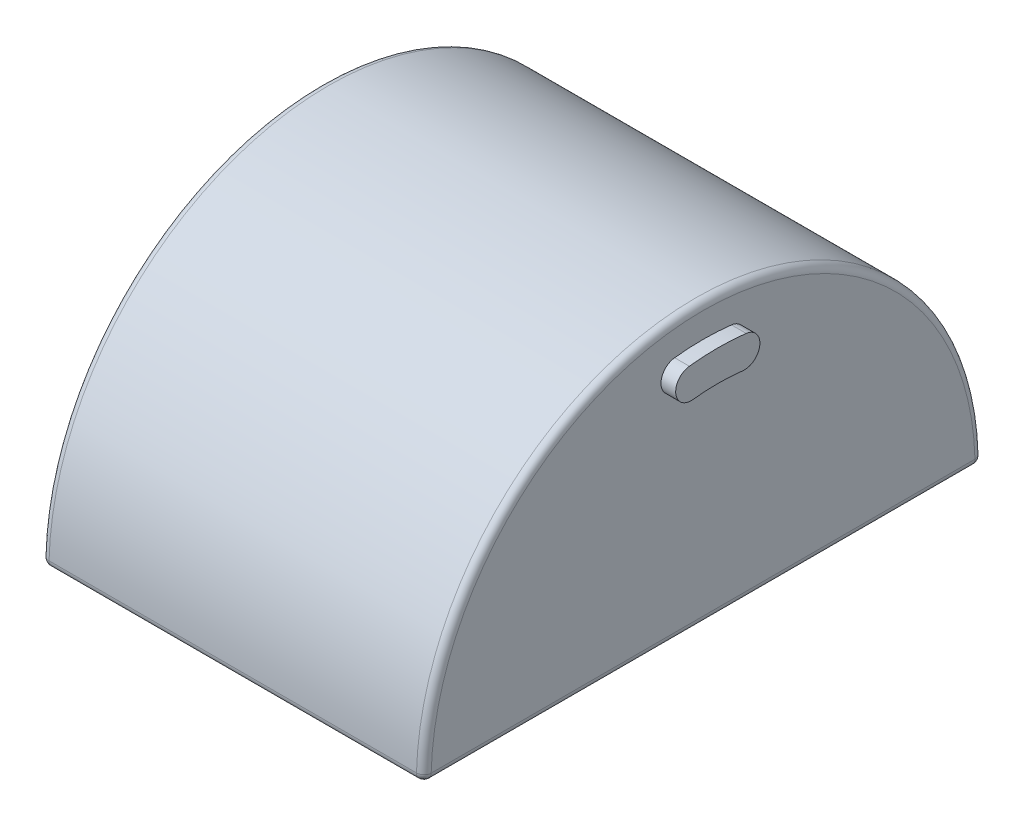
from build123d import *

# Parameters (mm, degrees)
MAIN_BODY_EXTRUDE_DEPTH = 16.51
INNER_HINGE_CUT_DEPTH   = 15.24
GROOVE_CUT_DEPTH        = 16.51
SLOT_START              = 16.51
SLOT_1_EXTRUDE_DEPTH    = 1.27
SLOT_START_2            = -16.51
SLOT_2_EXTRUDE_DEPTH    = 1.27
FILLET1_R               = 0.635


with BuildPart() as part:
    # Sketch6 → Main Body Extrude (new body, symmetric)
    with BuildSketch(Plane(origin=(0, 0, 0), x_dir=(0, 0, -1), z_dir=(1, 0, 0))):
        with BuildLine():
            ThreePointArc((24.138353817, 0), (0, 24.138353817), (-24.138353817, 0))
            Line((-24.138353817, 0), (24.138353817, 0))
        make_face()
        with BuildLine():
            ThreePointArc((2.45736216, 21.202424651), (3.628470035, 19.724266728), (2.150312111, 18.553158853))
            ThreePointArc((2.150312111, 18.553158853), (0, 18.677353817), (-2.150312111, 18.553158853))
            ThreePointArc((-2.150312111, 18.553158853), (-3.628470035, 19.724266728), (-2.45736216, 21.202424651))
            ThreePointArc((-2.45736216, 21.202424651), (0, 21.344353817), (2.45736216, 21.202424651))
        make_face(mode=Mode.SUBTRACT)
    extrude(amount=MAIN_BODY_EXTRUDE_DEPTH, both=True)

    # Sketch5_16 → Inner Hinge Cut (cut, symmetric)
    with BuildSketch(Plane.XY):
        with BuildLine():
            ThreePointArc((13.97, 0), (0, 13.97), (-13.97, 0))
            Line((-13.97, 0), (-12.7, 0))
            ThreePointArc((-12.7, 0), (0, 12.7), (12.7, 0))
            Line((12.7, 0), (13.97, 0))
        make_face()
        with BuildLine():
            ThreePointArc((12.446, 0), (0, 12.446), (-12.446, 0))
            Line((-12.446, 0), (-11.176, 0))
            ThreePointArc((-11.176, 0), (0, 11.176), (11.176, 0))
            Line((11.176, 0), (12.446, 0))
        make_face()
        with BuildLine():
            ThreePointArc((11.176, 0), (0, 11.176), (-11.176, 0))
            Line((-11.176, 0), (-8.636, 0))
            ThreePointArc((-8.636, 0), (0, 8.636), (8.636, 0))
            Line((8.636, 0), (11.176, 0))
        make_face()
        with BuildLine():
            ThreePointArc((8.636, 0), (0, 8.636), (-8.636, 0))
            Line((-8.636, 0), (8.636, 0))
        make_face()
        with BuildLine():
            ThreePointArc((12.7, 0), (0, 12.7), (-12.7, 0))
            Line((-12.7, 0), (-12.446, 0))
            ThreePointArc((-12.446, 0), (0, 12.446), (12.446, 0))
            Line((12.446, 0), (12.7, 0))
        make_face()
    extrude(amount=INNER_HINGE_CUT_DEPTH, both=True, mode=Mode.SUBTRACT)

    # Sketch5 → Groove Cut (cut, symmetric)
    with BuildSketch(Plane.XY):
        with BuildLine():
            ThreePointArc((11.176, 0), (0, 11.176), (-11.176, 0))
            Line((-11.176, 0), (-8.636, 0))
            ThreePointArc((-8.636, 0), (0, 8.636), (8.636, 0))
            Line((8.636, 0), (11.176, 0))
        make_face()
    extrude(amount=GROOVE_CUT_DEPTH, both=True, mode=Mode.SUBTRACT)

    # Fillet1
    fillet1_edges = [part.edges().sort_by_distance(p)[0] for p in [
        (0, 0, -24.138353817),
        (0, 0, 24.138353817),
        (16.51, 24.138353817, 0),
        (16.51, 0, 0),
        (-16.51, 0, 0),
        (-16.51, 24.138353817, 0),
    ]]
    fillet(fillet1_edges, radius=FILLET1_R)


with BuildPart() as body_2:
    # Sketch6_5 → Slot 1 Extrude (new body)
    with BuildSketch(Plane(origin=(0, 0, 0), x_dir=(0, 0, -1), z_dir=(1, 0, 0)).offset(SLOT_START)):
        with BuildLine():
            ThreePointArc((2.45736216, 21.202424651), (0, 21.344353817), (-2.45736216, 21.202424651))
            ThreePointArc((-2.45736216, 21.202424651), (-3.628470035, 19.724266728), (-2.150312111, 18.553158853))
            ThreePointArc((-2.150312111, 18.553158853), (0, 18.677353817), (2.150312111, 18.553158853))
            ThreePointArc((2.150312111, 18.553158853), (3.628470035, 19.724266728), (2.45736216, 21.202424651))
        make_face()
    extrude(amount=SLOT_1_EXTRUDE_DEPTH)


with BuildPart() as body_3:
    # Sketch6_6 → Slot 2 Extrude (new body)
    with BuildSketch(Plane(origin=(0, 0, 0), x_dir=(0, 0, -1), z_dir=(1, 0, 0)).offset(SLOT_START_2)):
        with BuildLine():
            ThreePointArc((2.45736216, 21.202424651), (0, 21.344353817), (-2.45736216, 21.202424651))
            ThreePointArc((-2.45736216, 21.202424651), (-3.628470035, 19.724266728), (-2.150312111, 18.553158853))
            ThreePointArc((-2.150312111, 18.553158853), (0, 18.677353817), (2.150312111, 18.553158853))
            ThreePointArc((2.150312111, 18.553158853), (3.628470035, 19.724266728), (2.45736216, 21.202424651))
        make_face()
    extrude(amount=-SLOT_2_EXTRUDE_DEPTH)


solid = Compound([part.part, body_2.part, body_3.part])
